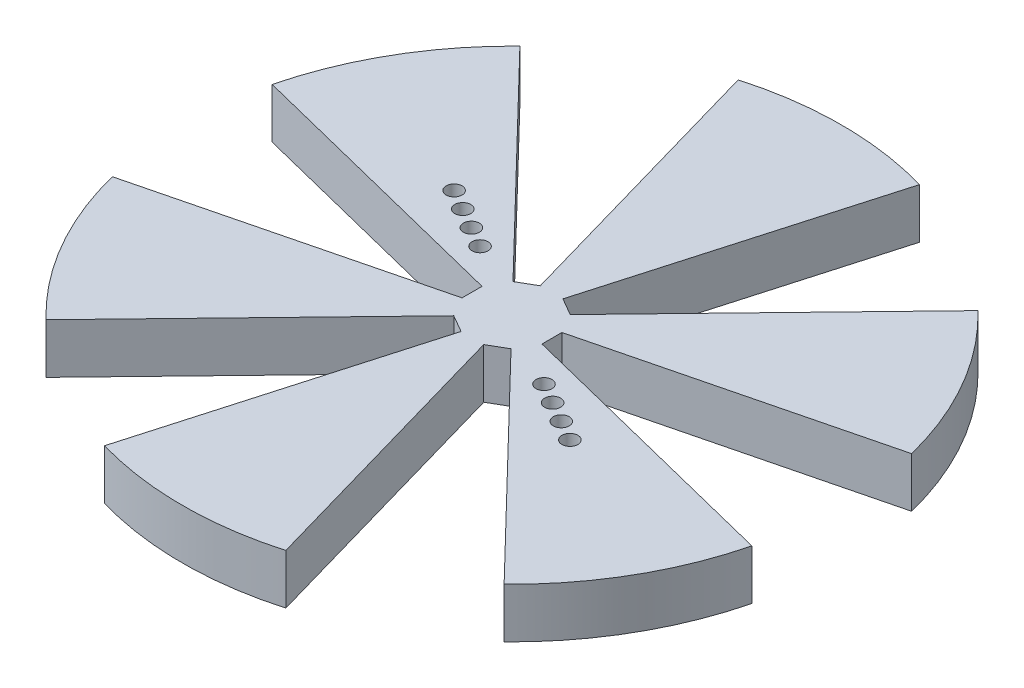
from build123d import *

# Parameters (mm, degrees)
SKETCH1_R           = 41.91
BOSS_EXTRUDE1_DEPTH = 6.35
CUT_EXTRUDE1_DEPTH  = 7.35
SKETCH3_R           = 1.016
CUT_EXTRUDE2_DEPTH  = 7.35


with BuildPart() as part:
    # Sketch1 → Boss-Extrude1 (new body)
    with BuildSketch(Plane(origin=(0, 0, 0), x_dir=(1, 0, 0), z_dir=(0, 1, 0))):
        Circle(SKETCH1_R)
    extrude(amount=BOSS_EXTRUDE1_DEPTH)

    # Sketch2 → Cut-Extrude1 (cut, through all)
    with BuildSketch(Plane(origin=(0, 6.35, 0), x_dir=(1, 0, 0), z_dir=(0, 1, 0))):
        with BuildLine():
            Line((-1.440684381, 5.03409922), (-11.531101351, 40.292453408))
            ThreePointArc((-11.531101351, 40.292453408), (-20.955, 36.295124673), (-29.128737556, 30.132453408))
            Line((-29.128737556, 30.132453408), (-3.639315619, 3.764718883))
            Line((-3.639315619, 3.764718883), (-1.440684381, 5.03409922))
        make_face()
        with BuildLine():
            Line((3.639315619, 3.764718883), (29.128737556, 30.132453408))
            ThreePointArc((29.128737556, 30.132453408), (20.955, 36.295124673), (11.531101351, 40.292453408))
            Line((11.531101351, 40.292453408), (1.440684381, 5.03409922))
            Line((1.440684381, 5.03409922), (3.639315619, 3.764718883))
        make_face()
        with BuildLine():
            Line((5.08, -1.269380337), (40.659838908, -10.16))
            ThreePointArc((40.659838908, -10.16), (41.596285583, -5.118312778), (41.91, 0))
            ThreePointArc((41.91, 0), (41.596285583, 5.118312778), (40.659838908, 10.16))
            Line((40.659838908, 10.16), (5.08, 1.269380337))
            Line((5.08, 1.269380337), (5.08, -1.269380337))
        make_face()
        with BuildLine():
            ThreePointArc((11.531101351, -40.292453408), (20.955, -36.295124673), (29.128737556, -30.132453408))
            Line((29.128737556, -30.132453408), (3.639315619, -3.764718883))
            Line((3.639315619, -3.764718883), (1.440684381, -5.03409922))
            Line((1.440684381, -5.03409922), (11.531101351, -40.292453408))
        make_face()
        with BuildLine():
            ThreePointArc((-29.128737556, -30.132453408), (-20.955, -36.295124673), (-11.531101351, -40.292453408))
            Line((-11.531101351, -40.292453408), (-1.440684381, -5.03409922))
            Line((-1.440684381, -5.03409922), (-3.639315619, -3.764718883))
            Line((-3.639315619, -3.764718883), (-29.128737556, -30.132453408))
        make_face()
        with BuildLine():
            ThreePointArc((-40.659838908, 10.16), (-41.91, 0), (-40.659838908, -10.16))
            Line((-40.659838908, -10.16), (-5.08, -1.269380337))
            Line((-5.08, -1.269380337), (-5.08, 1.269380337))
            Line((-5.08, 1.269380337), (-40.659838908, 10.16))
        make_face()
    extrude(amount=-CUT_EXTRUDE1_DEPTH, mode=Mode.SUBTRACT)

    # Sketch3 → Cut-Extrude2 (cut, through all)
    with BuildSketch(Plane(origin=(0, 6.35, 0), x_dir=(1, 0, 0), z_dir=(0, 1, 0))):
        with Locations((17.417935934, -10.05625)):
            Circle(SKETCH3_R)
        with Locations((-7.05625, -12.221783511)):
            Circle(SKETCH3_R)
        with Locations((-8.55625, -14.819859722)):
            Circle(SKETCH3_R)
        with Locations((-10.05625, -17.417935934)):
            Circle(SKETCH3_R)
        with Locations((-9.6237073, 5.55625)):
            Circle(SKETCH3_R)
        with Locations((5.55625, 9.6237073)):
            Circle(SKETCH3_R)
        with Locations((9.6237073, -5.55625)):
            Circle(SKETCH3_R)
        with Locations((-5.55625, -9.6237073)):
            Circle(SKETCH3_R)
        with Locations((-14.819859722, 8.55625)):
            Circle(SKETCH3_R)
        with Locations((-17.417935934, 10.05625)):
            Circle(SKETCH3_R)
        with Locations((-12.221783511, 7.05625)):
            Circle(SKETCH3_R)
        with Locations((7.05625, 12.221783511)):
            Circle(SKETCH3_R)
        with Locations((8.55625, 14.819859722)):
            Circle(SKETCH3_R)
        with Locations((10.05625, 17.417935934)):
            Circle(SKETCH3_R)
        with Locations((12.221783511, -7.05625)):
            Circle(SKETCH3_R)
        with Locations((14.819859722, -8.55625)):
            Circle(SKETCH3_R)
    extrude(amount=-CUT_EXTRUDE2_DEPTH, mode=Mode.SUBTRACT)


solid = part.part
